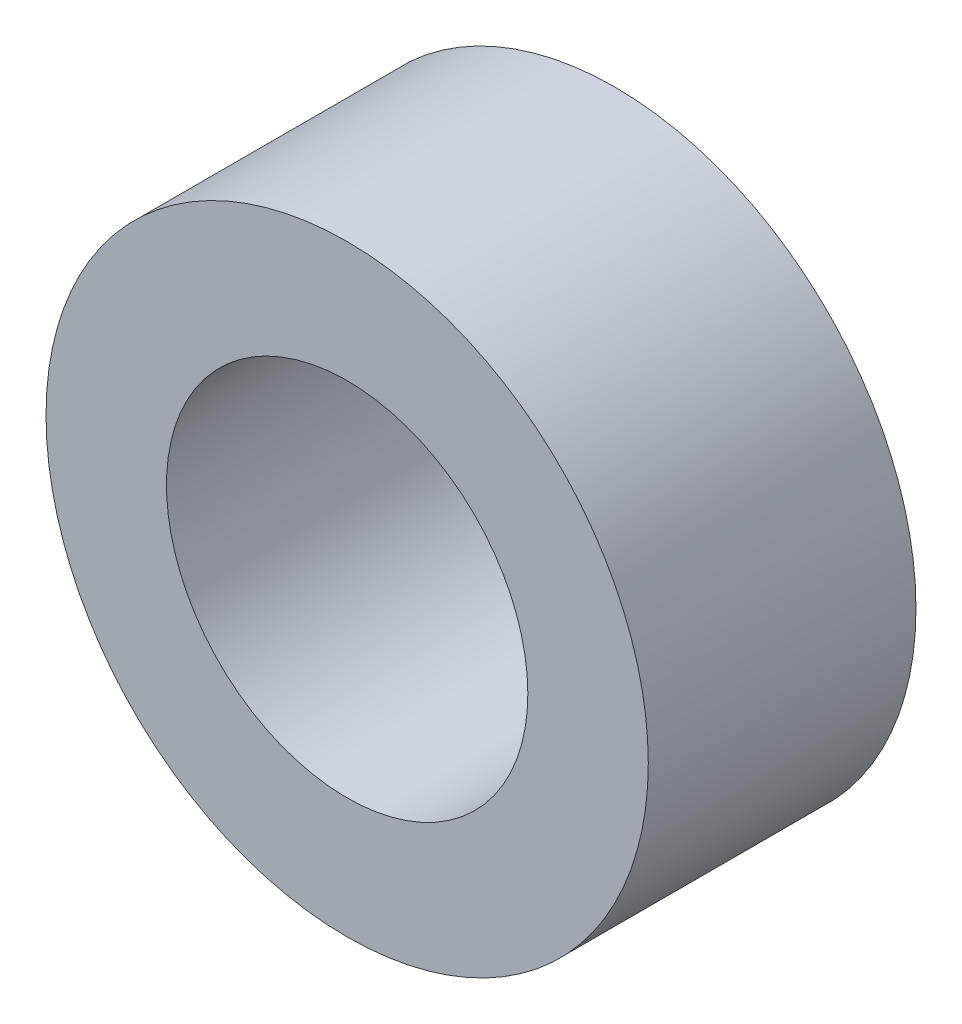
from build123d import *

# Parameters (mm, degrees)
SKETCH1_R      = 2.25
SKETCH1_R_2    = 1.35
EXTRUDE1_DEPTH = 1


with BuildPart() as part:
    # Sketch1 → Extrude1 (new body, symmetric)
    with BuildSketch(Plane.XY):
        Circle(SKETCH1_R)
        Circle(SKETCH1_R_2, mode=Mode.SUBTRACT)
    extrude(amount=EXTRUDE1_DEPTH, both=True)


solid = part.part
